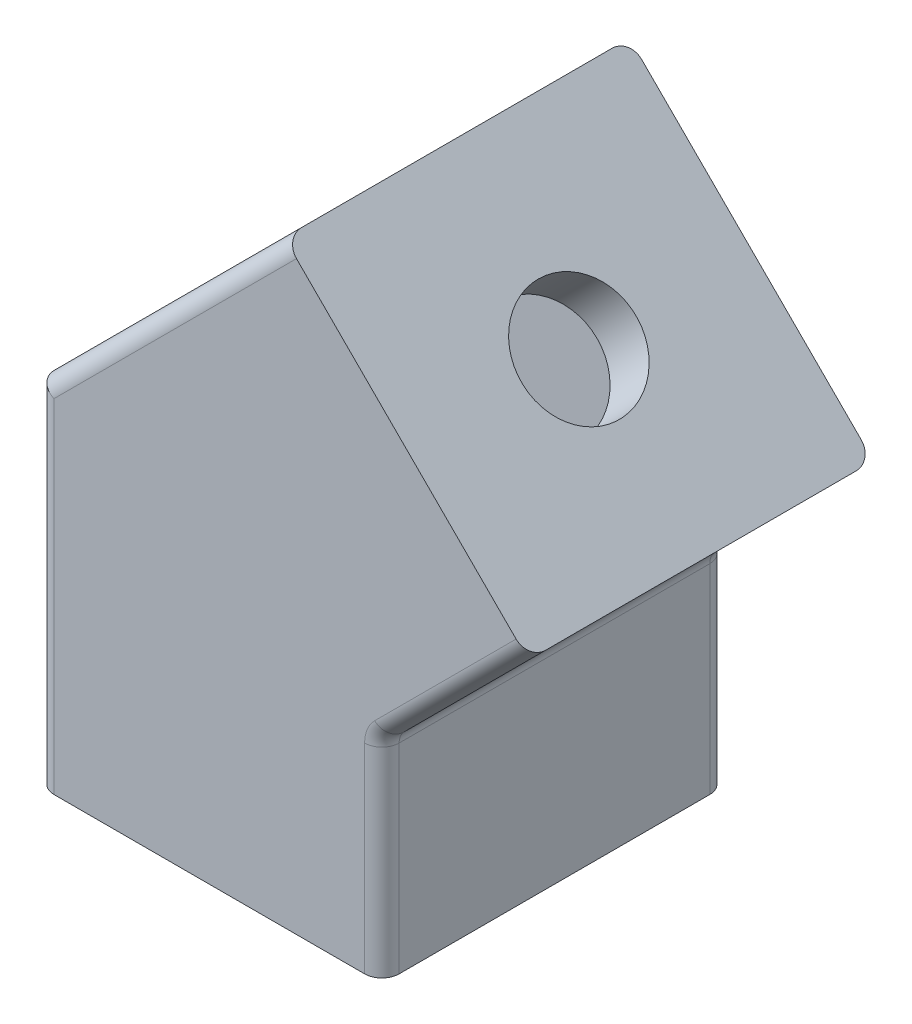
from build123d import *

# Parameters (mm, degrees)
BOSS_EXTRUDE1_DEPTH       = 20
SHELL1_T                  = -3.3
SHELL1_THICKNESS_2_FACE_W = 33.4
SHELL1_THICKNESS_2_FACE_H = 36.7
SHELL1_THICKNESS_2_DEPTH  = 6.7
SHELL1_THICKNESS_3_FACE_W = 36.7
SHELL1_THICKNESS_3_FACE_H = 33.4
SHELL1_THICKNESS_3_DEPTH  = 3.1
CUT_EXTRUDE1_REACH        = 84.439
SKETCH2_R                 = 6.65
CUT_EXTRUDE2_REACH        = 74.967
SKETCH3_R                 = 6.65
FILLET1_R                 = 2


with BuildPart() as part:
    # Sketch1 → Boss-Extrude1 (new, symmetric)
    with BuildSketch(Plane.XY):
        Polygon((0, -24), (0, 0), (16.970562748, 16.970562748), (-11.313708499, 45.254833996), (-40, 16.568542495), (-40, -24), align=None)
    extrude(amount=BOSS_EXTRUDE1_DEPTH, both=True)

    # Shell1
    shell1_openings = [part.faces().sort_by_distance(p)[0] for p in [
        (-40, -3.715728753, 0),
        (-25.656854249, 30.911688245, 0),
    ]]
    offset(amount=SHELL1_T, openings=shell1_openings, kind=Kind.INTERSECTION)

    # Shell1 thickness 2 face (on inner face of the shell) → Shell1 thickness 2 (add)
    with BuildSketch(Plane(origin=(-21.65, -20.7, 0), x_dir=(0, 0, -1), z_dir=(0, -1, 0))):
        Rectangle(SHELL1_THICKNESS_2_FACE_W, SHELL1_THICKNESS_2_FACE_H)
    extrude(amount=-SHELL1_THICKNESS_2_DEPTH)

    # Shell1 thickness 3 face (on inner face of the shell) → Shell1 thickness 3 (add)
    with BuildSketch(Plane(origin=(-0.671751442, 29.945972183, 0), x_dir=(-0.707106781187, 0.707106781187, 0), z_dir=(0.707106781187, 0.707106781187, 0))):
        Rectangle(SHELL1_THICKNESS_3_FACE_W, SHELL1_THICKNESS_3_FACE_H)
    extrude(amount=-SHELL1_THICKNESS_3_DEPTH)

    # Sketch2 → Cut-Extrude1 (cut, up to next)
    with BuildSketch(Plane.XZ.offset(24), mode=Mode.PRIVATE) as cut_extrude1_sk1:
        with Locations(Location((-20, 0, 0), (0, 0, 270))):
            Circle(SKETCH2_R)
    cut_extrude1_tool1 = extrude(cut_extrude1_sk1.sketch, amount=-CUT_EXTRUDE1_REACH, mode=Mode.PRIVATE) & part.part
    add(cut_extrude1_tool1.solids().sort_by_distance((-20, -24, 0))[0], mode=Mode.SUBTRACT)

    # Sketch3 → Cut-Extrude2 (cut, up to next)
    with BuildSketch(Plane(origin=(16.970562748, 16.970562748, 0), x_dir=(0, 0, -1), z_dir=(0.7071067811865488, 0.7071067811865462, 0)), mode=Mode.PRIVATE) as cut_extrude2_sk1:
        with Locations(Location((0, 20, 0), (0, 0, 90))):
            Circle(SKETCH3_R)
    cut_extrude2_tool1 = extrude(cut_extrude2_sk1.sketch, amount=-CUT_EXTRUDE2_REACH, mode=Mode.PRIVATE) & part.part
    add(cut_extrude2_tool1.solids().sort_by_distance((2.828427, 31.112698, 0))[0], mode=Mode.SUBTRACT)

    # Fillet1
    fillet1_edges = [part.edges().sort_by_distance(p)[0] for p in [
        (0, 0, 0),
        (8.485281374, 8.485281374, 20),
        (-25.656854249, 30.911688245, 20),
        (-3.3, 1.366904756, 0),
        (-40, -3.715728753, 20),
        (-40, -3.715728753, -20),
        (-25.656854249, 30.911688245, -20),
        (8.485281374, 8.485281374, -20),
        (0, -12, -20),
        (0, -12, 20),
    ]]
    fillet(fillet1_edges, radius=FILLET1_R)


solid = part.part
